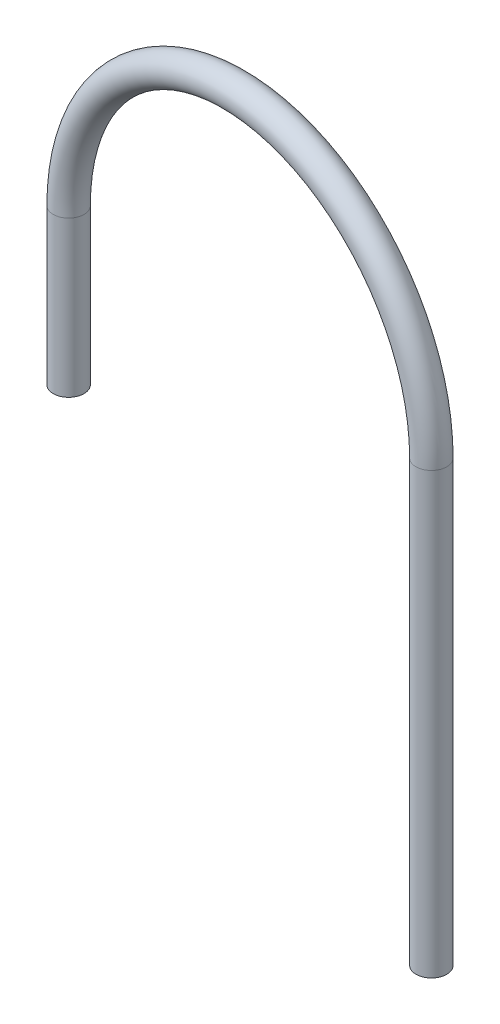
from build123d import *

# Parameters (mm, degrees)
BALAYAGE_MINCE1_PROFILE_R   = 3
BALAYAGE_MINCE1_PROFILE_R_2 = 2


with BuildPart() as part:
    # Balayage-Mince1: sweep along a curve in space
    with BuildLine() as balayage_mince1_path:
        Line((-42, 165, -59.25), (-42, 195.275, -59.25))
        ThreePointArc((-42, 195.275, -59.25), (-3, 234.443107243, -55.625), (36, 195.275, -52))
        Line((36, 195.275, -52), (36, 109.55, -52))
    # Balayage-Mince1 profile (on start of the path) → Balayage-Mince1 (sweep)
    with BuildSketch(Plane(origin=(-42, 165, -59.25), x_dir=(0, 0, 1), z_dir=(0, 1, 0))):
        Circle(BALAYAGE_MINCE1_PROFILE_R)
        Circle(BALAYAGE_MINCE1_PROFILE_R_2, mode=Mode.SUBTRACT)
    sweep(path=balayage_mince1_path.line)


solid = part.part
